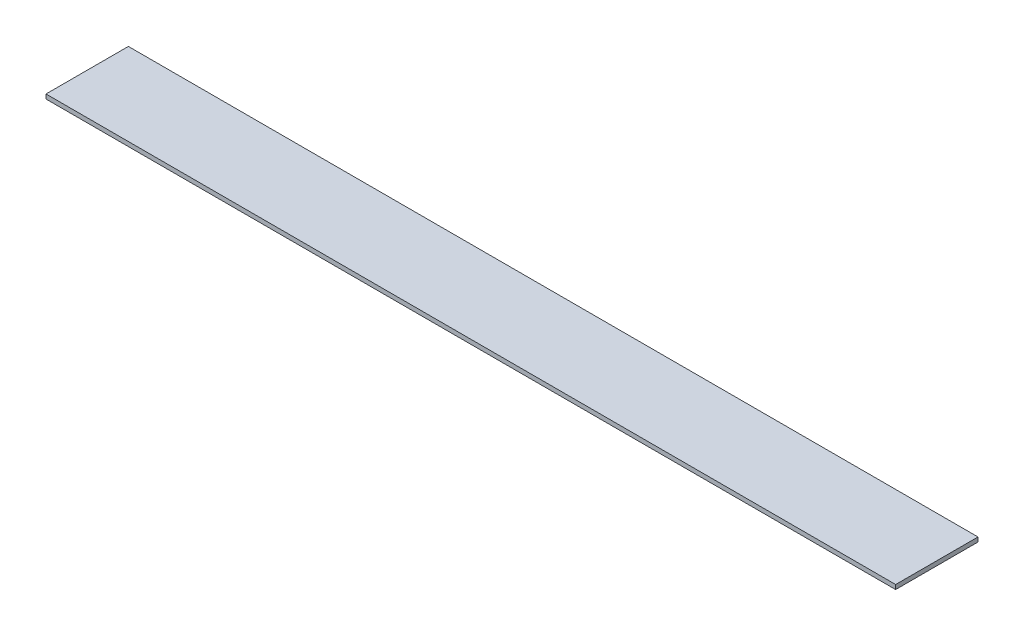
from build123d import *

# Parameters (mm, degrees)
SKETCH1_W           = 612.775
SKETCH1_H           = 59.4
BOSS_EXTRUDE1_DEPTH = 3.175


with BuildPart() as part:
    # Sketch1 → Boss-Extrude1 (new body)
    with BuildSketch(Plane(origin=(0, 0, 0), x_dir=(1, 0, 0), z_dir=(0, 1, 0))):
        with Locations((306.3875, 29.7)):
            Rectangle(SKETCH1_W, SKETCH1_H)
    extrude(amount=BOSS_EXTRUDE1_DEPTH)


solid = part.part
